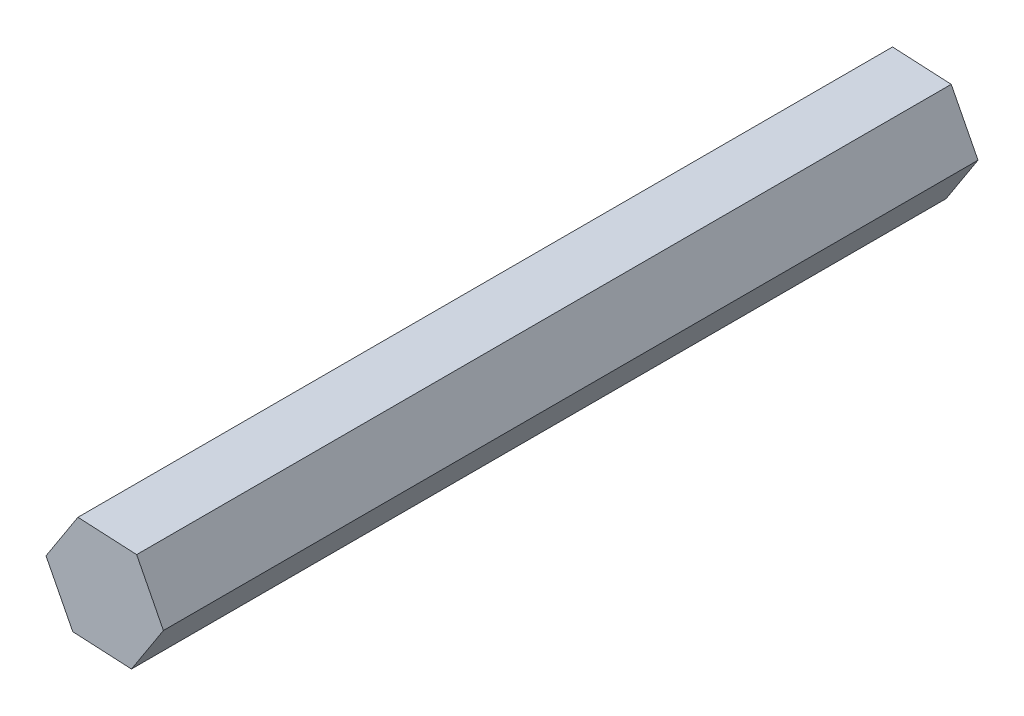
from build123d import *

# Parameters (mm, degrees)
BOSS_EXTRUDE1_DEPTH = 101.6


with BuildPart() as part:
    # Sketch1 → Boss-Extrude1 (new body)
    with BuildSketch(Plane.XY):
        Polygon((3.984540501, 6.155223012), (-3.338309244, 6.528324802), (-7.322849745, 0.37310179), (-3.984540501, -6.155223012), (3.338309244, -6.528324802), (7.322849745, -0.37310179), align=None)
    extrude(amount=BOSS_EXTRUDE1_DEPTH)


solid = part.part
